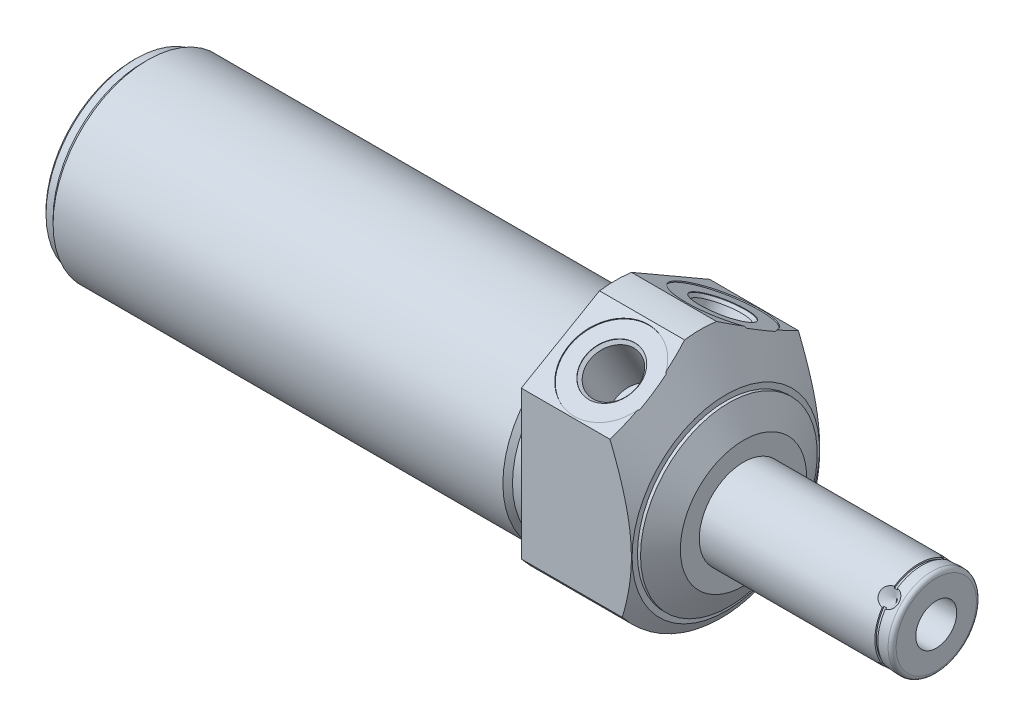
from build123d import *

# Parameters (mm, degrees)
SKETCH1_R           = 37.5
EXTRUDE1_DEPTH      = 32.1818
EXTRUDE1_DEPTH_BACK = 121.3612
CUT_EXTRUDE1_REACH  = 123.361
SKETCH2_R           = 37.5
SKETCH2_R_2         = 23.8125
SKETCH4_R           = 37.5
CUT_EXTRUDE3_DEPTH  = 32.1818
CHAMFER1_SIZE       = 0.762
CIRPATTERN1_COUNT   = 4
SKETCH21_W          = 0.762
SKETCH21_H          = 0.381


with BuildPart() as part:
    # Sketch1 → Extrude1 (new body, two sides)
    with BuildSketch(Plane(origin=(0, 0, 0), x_dir=(0, 0, -1), z_dir=(1, 0, 0))) as extrude1_sk:
        Circle(SKETCH1_R)
    extrude(amount=EXTRUDE1_DEPTH)
    extrude(extrude1_sk.sketch, amount=-EXTRUDE1_DEPTH_BACK)

    # Sketch2 → Cut-Extrude1 (cut, up to next)
    with BuildSketch(Plane(origin=(0, 0, 0), x_dir=(0, 0, -1), z_dir=(1, 0, 0)), mode=Mode.PRIVATE) as cut_extrude1_sk1:
        Circle(SKETCH2_R)
        with Locations((0, -4.445)):
            Circle(SKETCH2_R_2, mode=Mode.SUBTRACT)
    cut_extrude1_tool1 = extrude(cut_extrude1_sk1.sketch, amount=-CUT_EXTRUDE1_REACH, mode=Mode.PRIVATE) & part.part
    add(cut_extrude1_tool1.solids().sort_by_distance((0, 0, 36.43934))[0], mode=Mode.SUBTRACT)

    # Sketch4 → Cut-Extrude3 (cut)
    with BuildSketch(Plane.ZY.offset(-32.1818)):
        Circle(SKETCH4_R)
        with BuildLine():
            Line((23.6855, -18.675478468), (23.6855, 18.541912293))
            Line((23.6855, 18.541912293), (4.025382486, 29.892686431))
            ThreePointArc((4.025382486, 29.892686431), (0, 30.1625), (-4.025382486, 29.892686431))
            Line((-4.025382486, 29.892686431), (-23.6855, 18.541912293))
            Line((-23.6855, 18.541912293), (-23.6855, -18.675478468))
            ThreePointArc((-23.6855, -18.675478468), (0, -30.1625), (23.6855, -18.675478468))
        make_face(mode=Mode.SUBTRACT)
    extrude(amount=CUT_EXTRUDE3_DEPTH, mode=Mode.SUBTRACT)

    # Sketch6 → Cut-Revolve2 (revolve, cut)
    with BuildSketch(Plane.XY, mode=Mode.PRIVATE) as cut_revolve2_sk:
        Polygon((19.696600429, 33.055), (27.7368, 19.12896584), (27.7368, 17.78), (28.515625791, 17.78), (32.1818, 11.43), (32.1818, 33.055), align=None)
    revolve(cut_revolve2_sk.sketch.rotate(Axis((1.987224567, -4.445, 0), (1, 0, 0)), 90), axis=Axis((1.987224567, -4.445, 0), (1, 0, 0)), mode=Mode.SUBTRACT)  # turned: the seam where the file's is

    # S2D0002 → Cut-Revolve3 (revolve, cut)
    with BuildSketch(Plane(origin=(13.0048, 13.712414668, 8.609072086), x_dir=(0, 0.422618262, -0.906307787), z_dir=(1, 0, 0))):
        Polygon((6.088107567, 12.043122842), (10.161946165, 12.399537537), (10.139808606, 12.65257099), (-0.563506469, 11.716152259), (0.693906863, -2.656147889), (6.61488967, -2.138129017), (5.452667841, 11.146127282), (6.099176346, 11.916606116), align=None)
    cut_revolve3 = revolve(axis=Axis((13.0048, 3.062281243, 1.929320565), (0, 0.866025404, 0.5)), mode=Mode.SUBTRACT)

    # Mirror1: Cut-Revolve3 across plane
    add(cut_revolve3.mirror(Plane.XY), mode=Mode.SUBTRACT)

    # Sketch10 → Cut-Revolve6 (revolve, cut)
    with BuildSketch(Plane.XY, mode=Mode.PRIVATE) as cut_revolve6_sk:
        Polygon((0, 19.3675), (0, 18.161), (-3.302, 18.161), (-4.5085, 19.3675), align=None)
    revolve(cut_revolve6_sk.sketch.rotate(Axis((-5.09397, -4.445, 0), (1, 0, 0)), 90), axis=Axis((-5.09397, -4.445, 0), (1, 0, 0)), mode=Mode.SUBTRACT)  # turned: the seam where the file's is

    # Sketch12 → Cut-Revolve8 (revolve, cut)
    with BuildSketch(Plane.XY, mode=Mode.PRIVATE) as cut_revolve8_sk:
        Polygon((-121.3612, 19.3675), (-121.3612, 18.161), (-118.8212, 18.161), (-117.6147, 19.3675), align=None)
    revolve(cut_revolve8_sk.sketch.rotate(Axis((-50.92827, -4.445, 0), (1, 0, 0)), 90), axis=Axis((-50.92827, -4.445, 0), (1, 0, 0)), mode=Mode.SUBTRACT)  # turned: the seam where the file's is

    # Chamfer1
    chamfer1_edges = [part.edges().sort_by_distance(p)[0] for p in [
        (-121.3612, -4.445, -22.606),
    ]]
    chamfer(chamfer1_edges, length=CHAMFER1_SIZE)

    # Sketch13 → Revolve1 (revolve)
    with BuildSketch(Plane.XY, mode=Mode.PRIVATE) as revolve1_sk:
        with BuildLine():
            Line((32.1818, -4.445), (80.658, -4.445))
            Line((80.658, -4.445), (80.658, -14.5415))
            ThreePointArc((80.658, -14.5415), (80.36042049, -15.25992049), (79.642, -15.5575))
            Line((79.642, -15.5575), (32.1818, -15.5575))
            Line((32.1818, -15.5575), (32.1818, -4.445))
        make_face()
    revolve(revolve1_sk.sketch.rotate(Axis((4.7498, -4.445, 0), (1, 0, 0)), 270), axis=Axis((4.7498, -4.445, 0), (1, 0, 0)))  # turned: the seam where the file's is

    # S2D0001 → Cut-Revolve9 (revolve, cut)
    with BuildSketch(Plane.XY, mode=Mode.PRIVATE) as cut_revolve9_sk:
        Polygon((80.658, 0.7112), (63.64, 0.7112), (60.541842476, -4.445), (80.658, -4.445), align=None)
    revolve(cut_revolve9_sk.sketch.rotate(Axis((-2.8067, -4.445, 0), (-1, 0, 0)), 270), axis=Axis((-2.8067, -4.445, 0), (-1, 0, 0)), mode=Mode.SUBTRACT)  # turned: the seam where the file's is

    # Sketch16 → Cut-Revolve10 (revolve, cut)
    with BuildSketch(Plane(origin=(0, -7.588089642, 3.143089642), x_dir=(1, 0, 0), z_dir=(0, -0.707106781, -0.707106781)), mode=Mode.PRIVATE) as cut_revolve10_sk:
        Polygon((76.6956, -15.5575), (74.2826, -15.5575), (76.6956, -13.1445), align=None)
    cut_revolve10 = revolve(cut_revolve10_sk.sketch.rotate(Axis((76.6956, -5.128209126, 0.683209126), (0, -0.707106781, 0.707106781)), 270), axis=Axis((76.6956, -5.128209126, 0.683209126), (0, -0.707106781, 0.707106781)), mode=Mode.SUBTRACT)  # turned: the seam where the file's is

    # CirPattern1: Cut-Revolve10 ×4 about axis
    cirpattern1_axis = Axis((4.7498, -4.445, 0), (-1, 0, 0))
    for i in range(1, CIRPATTERN1_COUNT):
        add(cut_revolve10.rotate(cirpattern1_axis, i * 360 / CIRPATTERN1_COUNT), mode=Mode.SUBTRACT)

    # Sketch21 → Cut-Revolve11 (revolve, cut)
    with BuildSketch(Plane.XY, mode=Mode.PRIVATE) as cut_revolve11_sk:
        with Locations((76.6956, 6.477)):
            Rectangle(SKETCH21_W, SKETCH21_H)
    revolve(cut_revolve11_sk.sketch.rotate(Axis((23.873488058, -4.445, 0), (1, 0, 0)), 90), axis=Axis((23.873488058, -4.445, 0), (1, 0, 0)), mode=Mode.SUBTRACT)  # turned: the seam where the file's is


solid = part.part
